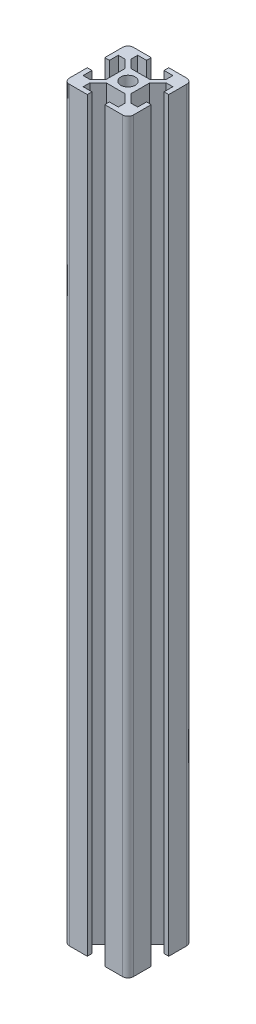
from build123d import *

# Parameters (mm, degrees)
SKETCH1_R           = 3.4
BOSS_EXTRUDE1_DEPTH = 350


with BuildPart() as part:
    # Sketch1 → Boss-Extrude1 (new body)
    with BuildSketch(Plane(origin=(0, 0, 0), x_dir=(1, 0, 0), z_dir=(0, 1, 0))):
        with BuildLine():
            Line((5.8, 4.385786438), (5.8, -4.385786438))
            Line((5.8, -4.385786438), (9.664213562, -8.25))
            Line((9.664213562, -8.25), (12.8, -8.25))
            Line((12.8, -8.25), (12.8, -4.1))
            Line((12.8, -4.1), (15, -4.1))
            Line((15, -4.1), (15, -12.5))
            ThreePointArc((15, -12.5), (14.267766953, -14.267766953), (12.5, -15))
            Line((12.5, -15), (4.1, -15))
            Line((4.1, -15), (4.1, -12.8))
            Line((4.1, -12.8), (8.25, -12.8))
            Line((8.25, -12.8), (8.25, -9.664213562))
            Line((8.25, -9.664213562), (4.385786438, -5.8))
            Line((4.385786438, -5.8), (-4.385786438, -5.8))
            Line((-4.385786438, -5.8), (-8.25, -9.664213562))
            Line((-8.25, -9.664213562), (-8.25, -12.8))
            Line((-8.25, -12.8), (-4.1, -12.8))
            Line((-4.1, -12.8), (-4.1, -15))
            Line((-4.1, -15), (-12.5, -15))
            ThreePointArc((-12.5, -15), (-14.267766953, -14.267766953), (-15, -12.5))
            Line((-15, -12.5), (-15, -4.1))
            Line((-15, -4.1), (-12.8, -4.1))
            Line((-12.8, -4.1), (-12.8, -8.25))
            Line((-12.8, -8.25), (-9.664213562, -8.25))
            Line((-9.664213562, -8.25), (-5.8, -4.385786438))
            Line((-5.8, -4.385786438), (-5.8, 4.385786438))
            Line((-5.8, 4.385786438), (-9.664213562, 8.25))
            Line((-9.664213562, 8.25), (-12.8, 8.25))
            Line((-12.8, 8.25), (-12.8, 4.1))
            Line((-12.8, 4.1), (-15, 4.1))
            Line((-15, 4.1), (-15, 12.5))
            ThreePointArc((-15, 12.5), (-14.267766953, 14.267766953), (-12.5, 15))
            Line((-12.5, 15), (-4.1, 15))
            Line((-4.1, 15), (-4.1, 12.8))
            Line((-4.1, 12.8), (-8.25, 12.8))
            Line((-8.25, 12.8), (-8.25, 9.664213562))
            Line((-8.25, 9.664213562), (-4.385786438, 5.8))
            Line((-4.385786438, 5.8), (4.385786438, 5.8))
            Line((4.385786438, 5.8), (8.25, 9.664213562))
            Line((8.25, 9.664213562), (8.25, 12.8))
            Line((8.25, 12.8), (4.1, 12.8))
            Line((4.1, 12.8), (4.1, 15))
            Line((4.1, 15), (12.5, 15))
            ThreePointArc((12.5, 15), (14.267766953, 14.267766953), (15, 12.5))
            Line((15, 12.5), (15, 4.1))
            Line((15, 4.1), (12.8, 4.1))
            Line((12.8, 4.1), (12.8, 8.25))
            Line((12.8, 8.25), (9.664213562, 8.25))
            Line((9.664213562, 8.25), (5.8, 4.385786438))
        make_face()
        Circle(SKETCH1_R, mode=Mode.SUBTRACT)
    extrude(amount=BOSS_EXTRUDE1_DEPTH)


solid = part.part
